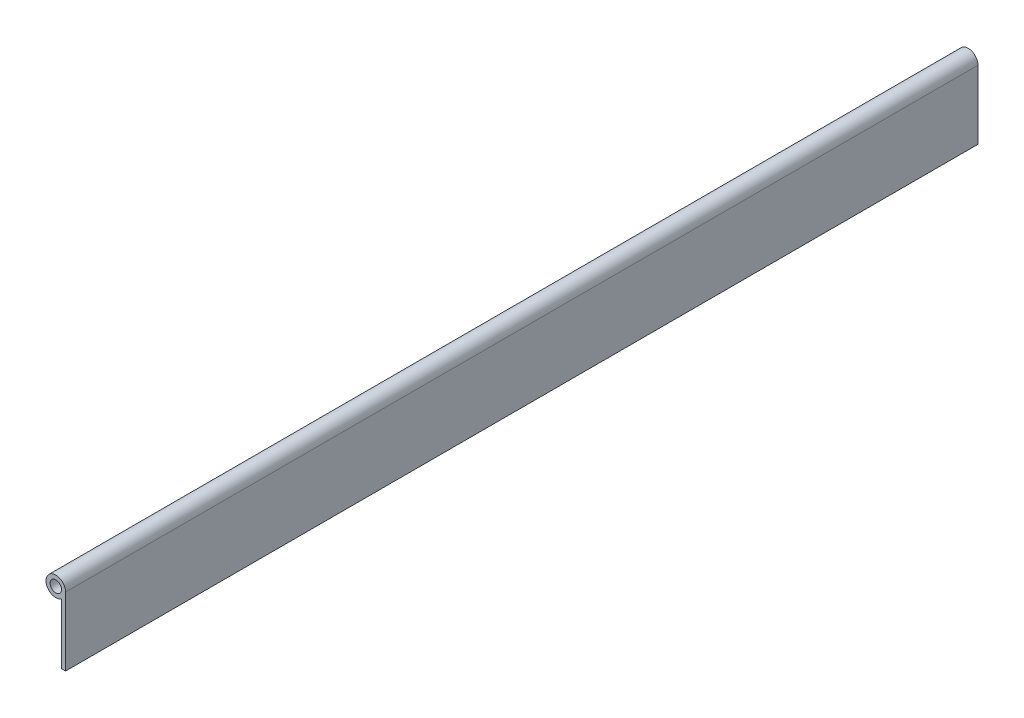
from build123d import *

# Parameters (mm, degrees)
SKETCH1_R           = 3.175
BOSS_EXTRUDE1_DEPTH = 508


with BuildPart() as part:
    # Sketch1 → Boss-Extrude1 (new body)
    with BuildSketch(Plane.XY):
        with BuildLine():
            Line((5.461, 0), (5.461, -38.1))
            Line((5.461, -38.1), (3.175, -38.1))
            Line((3.175, -38.1), (3.175, -4.443185344))
            ThreePointArc((3.175, -4.443185344), (-4.855985791, 2.498384078), (5.461, 0))
        make_face()
        Circle(SKETCH1_R, mode=Mode.SUBTRACT)
    extrude(amount=BOSS_EXTRUDE1_DEPTH)


solid = part.part
